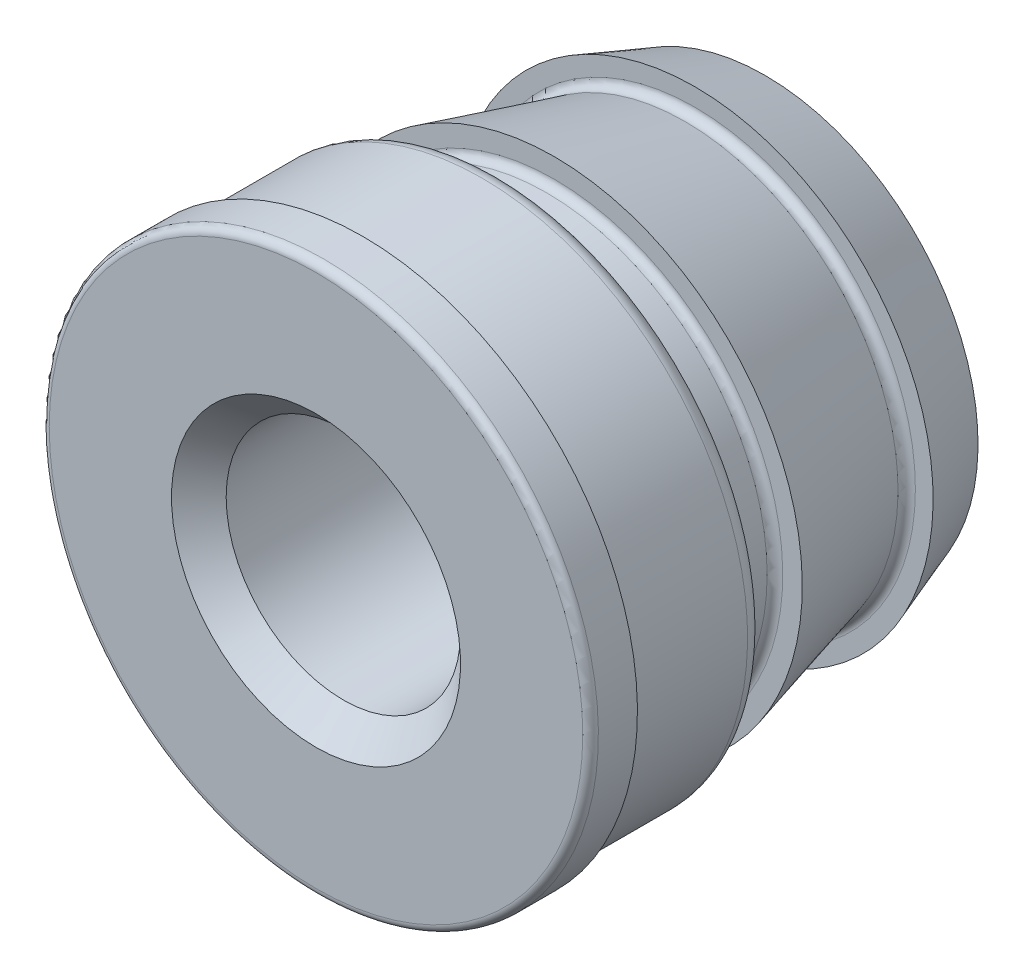
from build123d import *


with BuildPart() as part:
    # Sketch2 → Revolve1 (revolve)
    with BuildSketch(Plane(origin=(0, 0, 0), x_dir=(0, 0, -1), z_dir=(1, 0, 0))):
        with BuildLine():
            Line((-1.4605, 0.9398), (-1.4605, 1.73482))
            ThreePointArc((-1.4605, 1.73482), (-1.445621024, 1.770741024), (-1.4097, 1.78562))
            Line((-1.4097, 1.78562), (-1.1557, 1.78562))
            Line((-1.1557, 1.78562), (-1.1557, 1.7272))
            Line((-1.1557, 1.7272), (-0.381, 1.7272))
            ThreePointArc((-0.381, 1.7272), (-0.300177695, 1.693722305), (-0.2667, 1.6129))
            Line((-0.2667, 1.6129), (-0.2667, 1.4859))
            ThreePointArc((-0.2667, 1.4859), (-0.251821024, 1.449978976), (-0.2159, 1.4351))
            Line((-0.2159, 1.4351), (0.0381, 1.4351))
            ThreePointArc((0.0381, 1.4351), (0.074021024, 1.449978976), (0.0889, 1.4859))
            Line((0.0889, 1.4859), (0.0889, 1.6129))
            Line((0.0889, 1.6129), (0.939351993, 1.385022075))
            ThreePointArc((0.939351993, 1.385022075), (0.983425081, 1.393788758), (1.0033, 1.434091107))
            Line((1.0033, 1.434091107), (1.0033, 1.5494))
            Line((1.0033, 1.5494), (1.4605, 1.3843))
            Line((1.4605, 1.3843), (1.4605, 0.9398))
            Line((1.4605, 0.9398), (1.2827, 0.762))
            Line((1.2827, 0.762), (-1.2827, 0.762))
            Line((-1.2827, 0.762), (-1.4605, 0.9398))
        make_face()
    revolve(axis=Axis((0, 0, -1.4605), (0, 0, 1)))


solid = part.part
